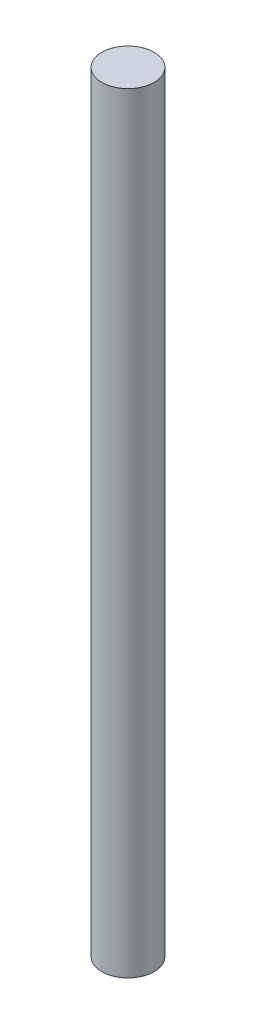
from build123d import *

# Parameters (mm, degrees)
SKETCH_1_R      = 2
EXTRUDE_1_DEPTH = 59


with BuildPart() as part:
    # 草图1 → 凸台-拉伸1 (new body)
    with BuildSketch(Plane(origin=(0, 0, 0), x_dir=(1, 0, 0), z_dir=(0, 1, 0))):
        Circle(SKETCH_1_R)
    extrude(amount=EXTRUDE_1_DEPTH)


solid = part.part
